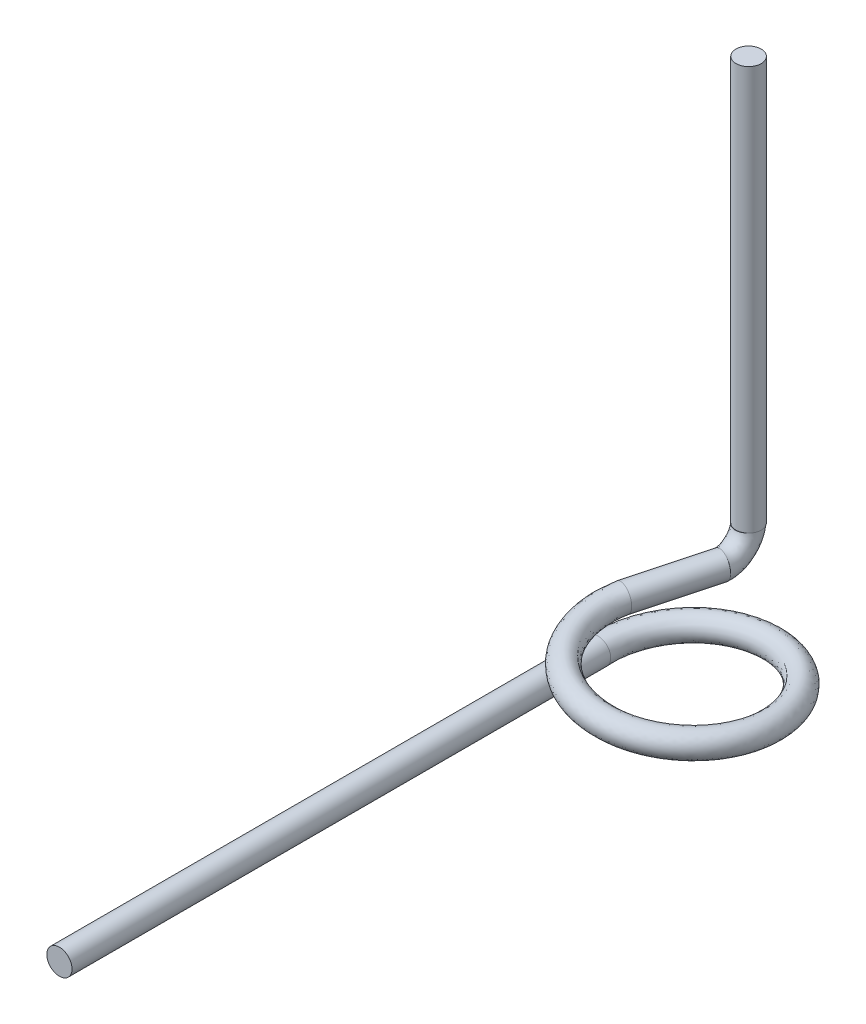
from build123d import *

# Parameters (mm, degrees)
SWEEP1_PITCH        = 6.604
SWEEP1_HEIGHT       = 6.879166887
SWEEP1_RADIUS       = 15.875
SWEEP1_START_ANGLE  = -90
SKETCH4_R           = 2.38125
SKETCH5_R           = 2.38125
BOSS_EXTRUDE1_DEPTH = 15.24
SKETCH6_R           = 2.38125
BOSS_EXTRUDE2_DEPTH = 101.6
SKETCH7_R           = 2.38125
SKETCH13_W          = 34.723649491
SKETCH13_H          = 34.72364949
CUT_EXTRUDE1_DEPTH  = 76.2
SKETCH15_R          = 2.38125
BOSS_EXTRUDE5_DEPTH = 76.2


with BuildPart() as part:
    # Sweep1: sweep along a helix
    with BuildLine() as sweep1_path:
        add(Helix(SWEEP1_PITCH, SWEEP1_HEIGHT, SWEEP1_RADIUS, center=(0, 0, 0), direction=(0, 1, 0), lefthand=True, mode=Mode.PRIVATE).rotate(Axis((0, 0, 0), (0, 1, 0)), SWEEP1_START_ANGLE))
    # Sketch4 → Sweep1 (sweep)
    with BuildSketch(Plane.XY):
        with Locations((-15.875, 0)):
            Circle(SKETCH4_R)
    sweep(path=sweep1_path.line, is_frenet=True)

    # Sketch5 → Boss-Extrude1 (add)
    with BuildSketch(Plane(origin=(0, 0, 0), x_dir=(-0.965925772, 0, -0.258819247), z_dir=(0.258819247, 0, -0.965925772))):
        with Locations((15.875, 6.879489502)):
            Circle(SKETCH5_R)
    extrude(amount=BOSS_EXTRUDE1_DEPTH)

    # Sketch6 → Boss-Extrude2 (add)
    with BuildSketch(Plane.XY):
        with Locations((-15.875, 0)):
            Circle(SKETCH6_R)
    extrude(amount=BOSS_EXTRUDE2_DEPTH)

    # Sweep3: sweep along a path in Sketch8
    with BuildLine(Plane(origin=(-11.389666301, -1.880573246, 0), x_dir=(0, -1, 0), z_dir=(1, 0, 0))) as sweep3_path:
        ThreePointArc((-8.760062748, 18.829464319), (-10.247960299, 22.421566768), (-13.840062748, 23.909464319))
    # Sketch7 → Sweep3 (sweep)
    with BuildSketch(Plane(origin=(3.94440533, 0, -14.720708767), x_dir=(-0.965925772, 0, -0.258819247), z_dir=(0.258819247, 0, -0.965925772))):
        with Locations((15.875, 6.879489502)):
            Circle(SKETCH7_R)
    sweep(path=sweep3_path.line)

    # Sketch13 → Cut-Extrude1 (cut)
    with BuildSketch(Plane(origin=(0, 0, 0), x_dir=(0, 0, -1), z_dir=(1, 0, 0))):
        with Locations((15.752675198, 28.559314247)):
            Rectangle(SKETCH13_W, SKETCH13_H)
    extrude(amount=-CUT_EXTRUDE1_DEPTH, mode=Mode.SUBTRACT)

    # Sketch15 → Boss-Extrude5 (add)
    with BuildSketch(Plane(origin=(0, 11.197489502, 0), x_dir=(1, 0, 0), z_dir=(0, 1, 0))):
        with Locations((-11.372091381, 23.873869709)):
            Circle(SKETCH15_R)
    extrude(amount=BOSS_EXTRUDE5_DEPTH)


solid = part.part
